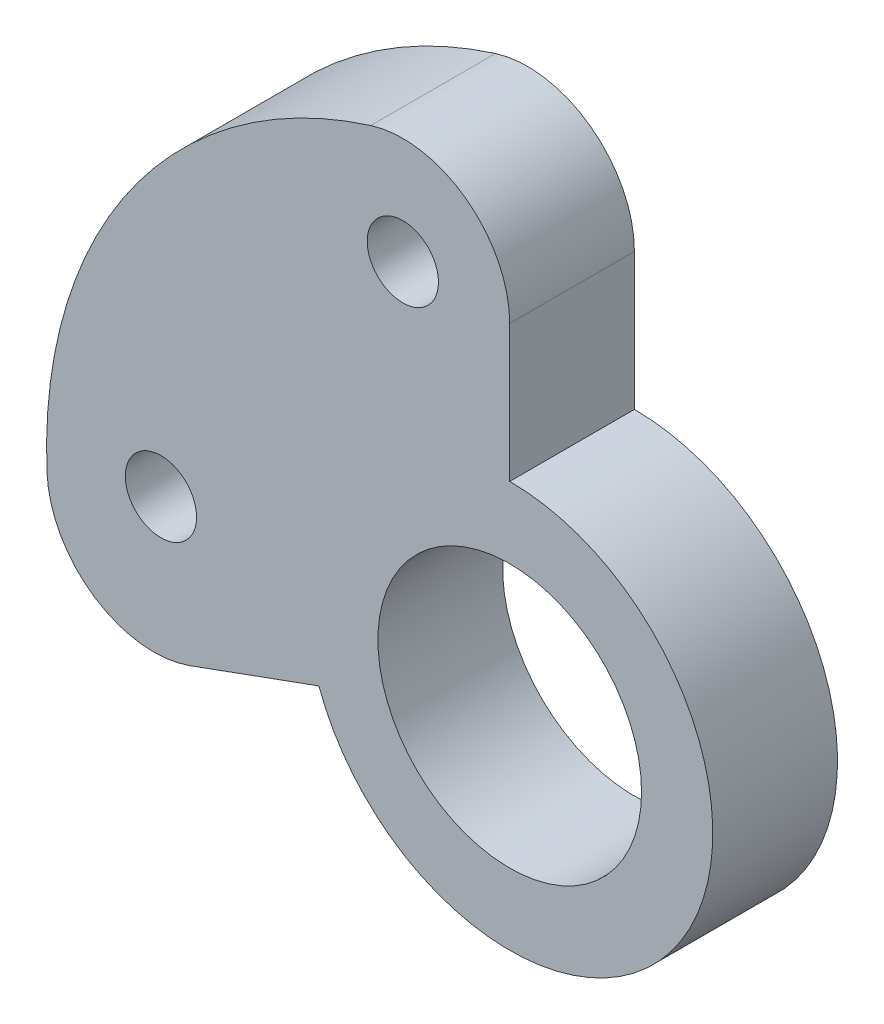
from build123d import *
from build123d.topology import SkipClean

# Parameters (mm, degrees)
SKETCH1_R           = 13
SKETCH1_R_2         = 3.7
BOSS_EXTRUDE1_DEPTH = 3.5
CUT_EXTRUDE1_START  = -10
CUT_EXTRUDE1_DEPTH  = 10
SKETCH3_R           = 1
CUT_EXTRUDE2_DEPTH  = 10
SKETCH5_R           = 1
CUT_EXTRUDE3_DEPTH  = 6
FILLET1_R           = 3
SKETCH6_R           = 2
SKETCH6_R_2         = 1
BOSS_EXTRUDE2_DEPTH = 2
SKETCH6_3_R         = 2
SKETCH6_3_R_2       = 1
BOSS_EXTRUDE3_DEPTH = 0.5


with BuildPart() as part:
    # Sketch1 → Boss-Extrude1 (new body)
    with BuildSketch(Plane.XY):
        Circle(SKETCH1_R)
        Circle(SKETCH1_R_2, mode=Mode.SUBTRACT)
    extrude(amount=BOSS_EXTRUDE1_DEPTH)

    # Sketch2 → Cut-Extrude1 (cut)
    with BuildSketch(Plane.XY.offset(3.5).offset(CUT_EXTRUDE1_START)):
        with BuildLine():
            ThreePointArc((5.7, 0), (0.989794613, -5.613404192), (-5.356247938, -1.949514817))
            Line((-5.356247938, -1.949514817), (-12.21600407, -4.446261863))
            ThreePointArc((-12.21600407, -4.446261863), (2.25742631, -12.802500789), (13, 0))
            ThreePointArc((13, 0), (9.192388155, 9.192388155), (0, 13))
            Line((0, 13), (0, 5.7))
            ThreePointArc((0, 5.7), (4.030508653, 4.030508653), (5.7, 0))
        make_face()
    extrude(amount=CUT_EXTRUDE1_DEPTH, mode=Mode.SUBTRACT)

    # Sketch3 → Cut-Extrude2 (cut)
    with BuildSketch(Plane.XY.offset(3.5)):
        with Locations((-3, 9.539392014)):
            Circle(SKETCH3_R)
    extrude(amount=-CUT_EXTRUDE2_DEPTH, mode=Mode.SUBTRACT)

    # Sketch5 → Cut-Extrude3 (cut)
    with BuildSketch(Plane.XY.offset(3.5)):
        with Locations((-9.790353578, 0.434714634)):
            Circle(SKETCH5_R)
    extrude(amount=-CUT_EXTRUDE3_DEPTH, mode=Mode.SUBTRACT)

    # Fillet1
    fillet1_edges = [part.edges().sort_by_distance(p)[0] for p in [
        (-12.21600407, -4.446261863, 1.75),
        (0, 13, 1.75),
    ]]
    fillet(fillet1_edges, radius=FILLET1_R)

    # Sketch6 → Boss-Extrude2 (add)
    with SkipClean():  # the faces are left unmerged after this step: merging them gives an invalid solid
        with BuildSketch(Plane(origin=(0, 0, 0), x_dir=(-1, 0, 0), z_dir=(0, 0, -1))):
            with Locations((9.790353578, 0.434714634)):
                Circle(SKETCH6_R)
            with Locations((9.790353578, 0.434714634)):
                Circle(SKETCH6_R_2, mode=Mode.SUBTRACT)
        extrude(amount=BOSS_EXTRUDE2_DEPTH)

    # Sketch6_3 → Boss-Extrude3 (add)
    with SkipClean():  # the faces are left unmerged after this step: merging them gives an invalid solid
        with BuildSketch(Plane(origin=(0, 0, 0), x_dir=(-1, 0, 0), z_dir=(0, 0, -1))):
            with Locations((3, 9.539392014)):
                Circle(SKETCH6_3_R)
            with Locations((3, 9.539392014)):
                Circle(SKETCH6_3_R_2, mode=Mode.SUBTRACT)
        extrude(amount=BOSS_EXTRUDE3_DEPTH)


solid = part.part
